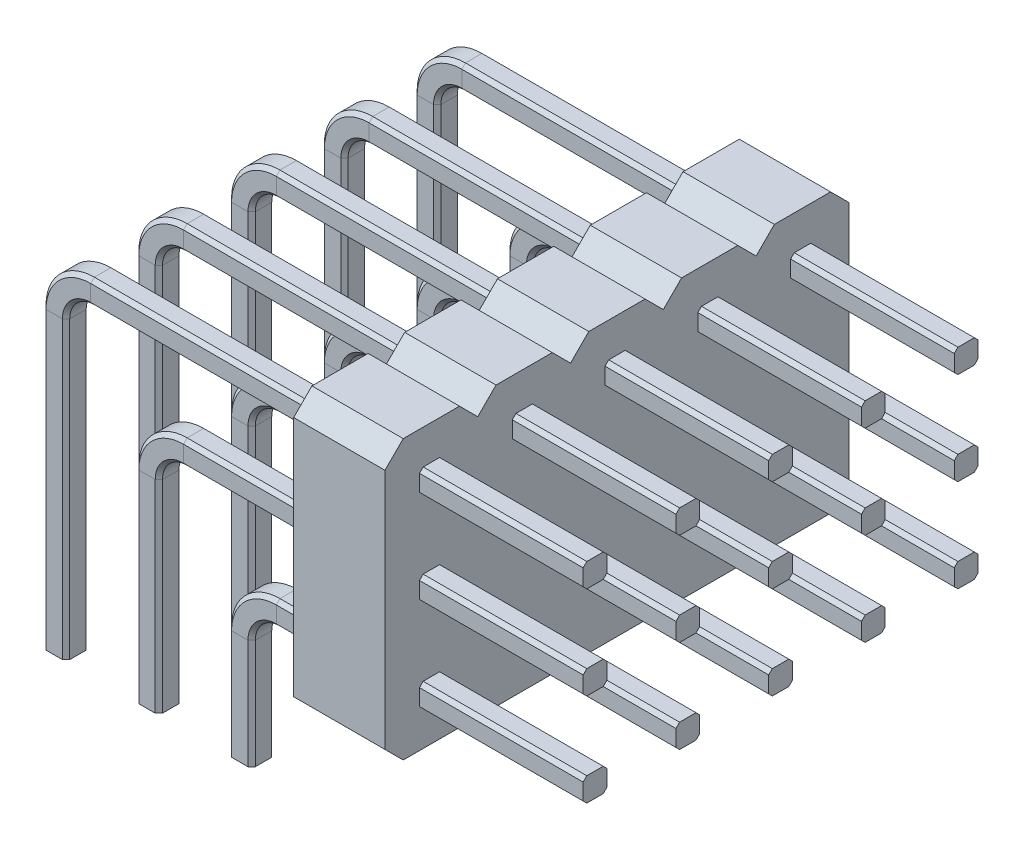
from build123d import *

# Parameters (mm, degrees)
BOSS_EXTRUDE1_DEPTH = 2.5
LPATTERN1_COUNT     = 5
LPATTERN1_PITCH     = 2.54


with BuildPart() as part:
    # Sweep2: sweep along a path in Sketch2
    with BuildLine(Plane.XY) as sweep2_path:
        Line((5.08, 0), (5.08, 3))
        ThreePointArc((5.08, 3), (5.372893219, 3.707106781), (6.08, 4))
        Line((6.08, 4), (14.48, 4))
    # Sketch1 → Sweep2 (sweep)
    with BuildSketch(Plane(origin=(0, 0, 0), x_dir=(1, 0, 0), z_dir=(0, 1, 0))):
        Polygon((5.305, 0.325), (4.855, 0.325), (4.755, 0.225), (4.755, -0.225), (4.855, -0.325), (5.305, -0.325), (5.405, -0.225), (5.405, 0.225), align=None)
    sweep(path=sweep2_path.line)



with BuildPart() as body_2:
    # Sweep3: sweep along a path in Sketch2_3
    with BuildLine(Plane.XY) as sweep3_path:
        Line((2.54, 0), (2.54, 5.54))
        ThreePointArc((2.54, 5.54), (2.832893219, 6.247106781), (3.54, 6.54))
        Line((3.54, 6.54), (14.48, 6.54))
    # Sketch1_3 → Sweep3 (sweep)
    with BuildSketch(Plane(origin=(0, 0, 0), x_dir=(1, 0, 0), z_dir=(0, 1, 0))):
        Polygon((2.765, 0.325), (2.315, 0.325), (2.215, 0.225), (2.215, -0.225), (2.315, -0.325), (2.765, -0.325), (2.865, -0.225), (2.865, 0.225), align=None)
    sweep(path=sweep3_path.line)


with BuildPart() as body_3:
    # Sweep4: sweep along a path in Sketch2_4
    with BuildLine(Plane.XY) as sweep4_path:
        Line((0, 0), (0, 8.08))
        ThreePointArc((0, 8.08), (0.292893219, 8.787106781), (1, 9.08))
        Line((1, 9.08), (14.48, 9.08))
    # Sketch1_4 → Sweep4 (sweep)
    with BuildSketch(Plane(origin=(0, 0, 0), x_dir=(1, 0, 0), z_dir=(0, 1, 0))):
        Polygon((-0.225, 0.325), (-0.325, 0.225), (-0.325, -0.225), (-0.225, -0.325), (0.225, -0.325), (0.325, -0.225), (0.325, 0.225), (0.225, 0.325), align=None)
    sweep(path=sweep4_path.line)


with BuildPart() as part_1:
    add(part.part)

    add(body_2.part)  # Boss-Extrude1 merges body 2

    add(body_3.part)  # Boss-Extrude1 merges body 3
    # Sketch3 → Boss-Extrude1 (add)
    with BuildSketch(Plane(origin=(7.5, 0, 0), x_dir=(0, 0, -1), z_dir=(1, 0, 0))):
        Polygon((-0.77, 2.73), (0.77, 2.73), (1.27, 3.23), (1.27, 9.85), (0.77, 10.35), (-0.77, 10.35), (-1.27, 9.85), (-1.27, 3.23), align=None)
    extrude(amount=BOSS_EXTRUDE1_DEPTH)


with BuildPart() as lpattern1_1:
    # LPattern1: pattern copy
    add(part_1.part.moved(Location(Vector(0, 0, -1) * (1 * LPATTERN1_PITCH))))


with BuildPart() as lpattern1_2:
    # LPattern1: pattern copy
    add(part_1.part.moved(Location(Vector(0, 0, -1) * (2 * LPATTERN1_PITCH))))


with BuildPart() as lpattern1_3:
    # LPattern1: pattern copy
    add(part_1.part.moved(Location(Vector(0, 0, -1) * (3 * LPATTERN1_PITCH))))


with BuildPart() as lpattern1_4:
    # LPattern1: pattern copy
    add(part_1.part.moved(Location(Vector(0, 0, -1) * (4 * LPATTERN1_PITCH))))

    # Combine1: union LPattern1_3, LPattern1_2, LPattern1_1, part
    add(lpattern1_3.part)
    add(lpattern1_2.part)
    add(lpattern1_1.part)
    add(part_1.part)


solid = lpattern1_4.part
